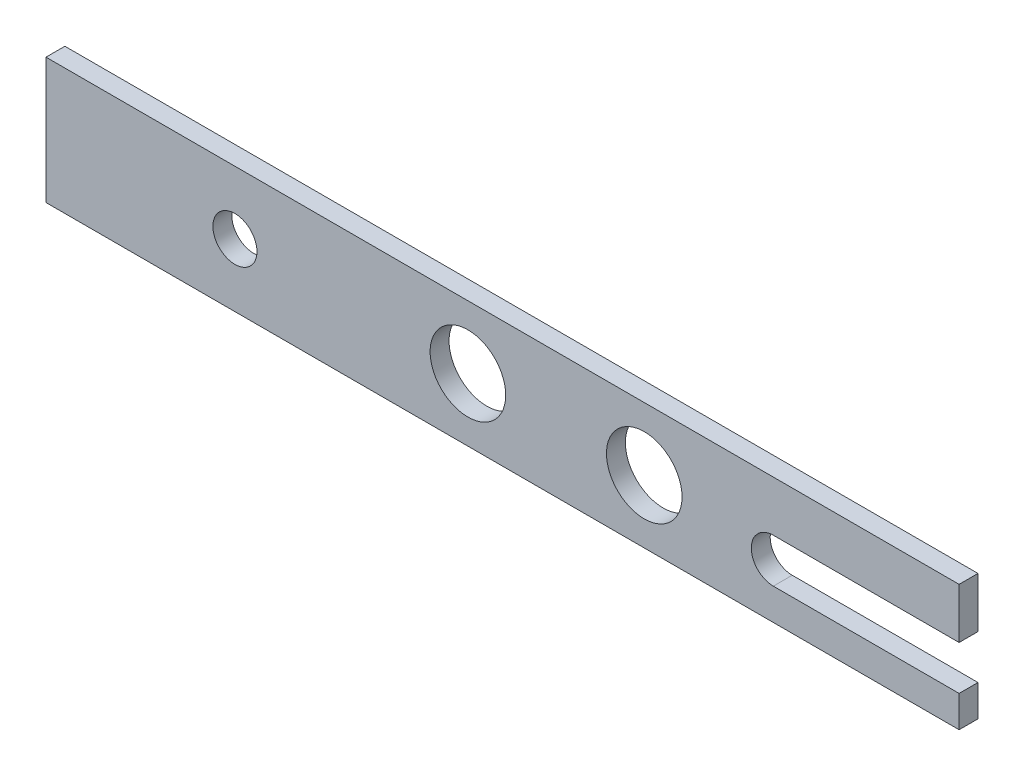
from build123d import *

# Parameters (mm, degrees)
SKETCH1_R           = 3.5
SKETCH1_R_2         = 6
BOSS_EXTRUDE1_DEPTH = 3


with BuildPart() as part:
    # Sketch1 → Boss-Extrude1 (new body)
    with BuildSketch(Plane.XY):
        with BuildLine():
            Line((0, 20), (0, 0))
            Line((0, 0), (145, 0))
            Line((145, 0), (145, 5))
            Line((145, 5), (115.5, 5))
            ThreePointArc((115.5, 5), (112, 8.5), (115.5, 12))
            Line((115.5, 12), (145, 12))
            Line((145, 12), (145, 20))
            Line((145, 20), (0, 20))
        make_face()
        with Locations((30, 10)):
            Circle(SKETCH1_R, mode=Mode.SUBTRACT)
        with Locations((67, 10)):
            Circle(SKETCH1_R_2, mode=Mode.SUBTRACT)
        with Locations((95, 10)):
            Circle(SKETCH1_R_2, mode=Mode.SUBTRACT)
    extrude(amount=BOSS_EXTRUDE1_DEPTH)


solid = part.part
